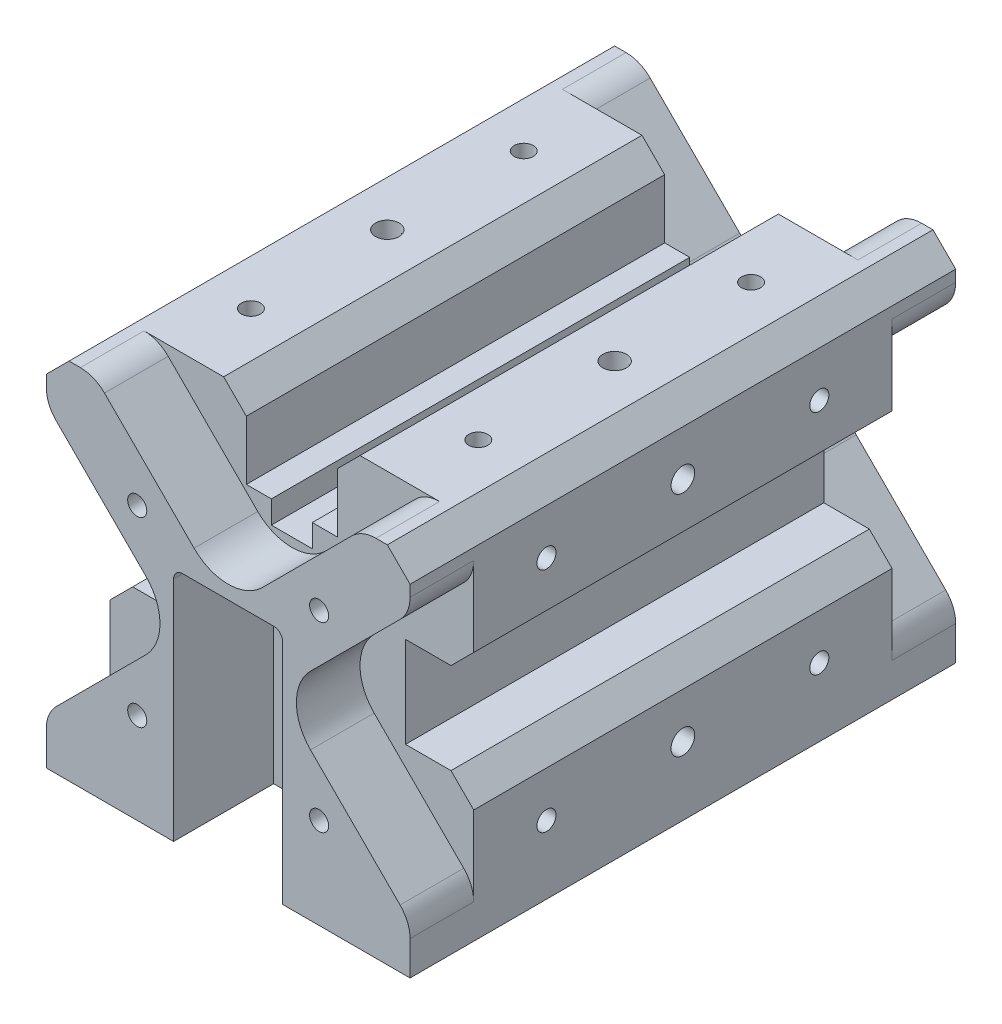
from build123d import *

# Parameters (mm, degrees)
SKETCH_7_W                = 80
SKETCH_7_H                = 80
EXTRUDE_2_DEPTH           = 120
CUT_EXTRUDE_2_DEPTH       = 22
CUT_EXTRUDE6_DEPTH        = 22
SKETCH5_R                 = 2
CUT_EXTRUDE8_DEPTH        = 10
SKETCH_10_R               = 2
CUT_EXTRUDE9_DEPTH        = 10
M3X0_5_TAPPED_HOLE1_D     = 2.5
M3X0_5_TAPPED_HOLE1_DEPTH = 7.5
M3X0_5_TAPPED_HOLE1_TIP   = 0.751075774
M5X0_8_TAPPED_HOLE2_D     = 4.2
M5X0_8_TAPPED_HOLE2_DEPTH = 19
M5X0_8_TAPPED_HOLE2_TIP   = 1.2618073
M5X0_8_TAPPED_HOLE5_D     = 4.2
M5X0_8_TAPPED_HOLE5_DEPTH = 12.4
M5X0_8_TAPPED_HOLE5_TIP   = 1.2618073
M5X0_8_TAPPED_HOLE3_D     = 4.2
M5X0_8_TAPPED_HOLE3_DEPTH = 12.4
M5X0_8_TAPPED_HOLE3_TIP   = 1.2618073
M5X0_8_TAPPED_HOLE4_D     = 4.2
M5X0_8_TAPPED_HOLE4_DEPTH = 12.4
M5X0_8_TAPPED_HOLE4_TIP   = 1.2618073
M3X0_5_TAPPED_HOLE4_D     = 2.5
M3X0_5_TAPPED_HOLE4_DEPTH = 5.5
M3X0_5_TAPPED_HOLE4_TIP   = 0.751075774
M3X0_5_TAPPED_HOLE5_D     = 2.5
M3X0_5_TAPPED_HOLE5_DEPTH = 5.5
M3X0_5_TAPPED_HOLE5_TIP   = 0.751075774
M5X0_8_TAPPED_HOLE1_D     = 4.2
M5X0_8_TAPPED_HOLE1_DEPTH = 19
M5X0_8_TAPPED_HOLE1_TIP   = 1.2618073
SKETCH33_R                = 2.6
CUT_EXTRUDE16_DEPTH       = 11
CUT_EXTRUDE16_TAPER       = 0.573055556
SKETCH34_R                = 2.6
CUT_EXTRUDE17_DEPTH       = 11
CUT_EXTRUDE17_TAPER       = 0.573055556
SKETCH35_R                = 2.6
CUT_EXTRUDE18_DEPTH       = 11
CUT_EXTRUDE18_TAPER       = 0.573055556
SKETCH63_OUTSIDE_W        = 114.984
SKETCH63_OUTSIDE_H        = 114.984
CUT_EXTRUDE19_DEPTH       = 121
CHAMFER1_SIZE             = 5
SKETCH_11_W               = 9
SKETCH_11_H               = 5
CUT_EXTRUDE_3_DEPTH       = 121
CUT_EXTRUDE_4_DEPTH       = 14
SKETCH64_OUTSIDE_W        = 114.984
SKETCH64_OUTSIDE_H        = 114.984
CUT_EXTRUDE_6_DEPTH       = 14


with BuildPart() as part:
    # Эскиз7 → Бобышка-Вытянуть2 (new body)
    with BuildSketch(Plane.XY):
        Rectangle(SKETCH_7_W, SKETCH_7_H)
    extrude(amount=EXTRUDE_2_DEPTH)

    # Эскиз8 → Вырез-Вытянуть2 (cut)
    with BuildSketch(Plane(origin=(0, 0, 0), x_dir=(-1, 0, 0), z_dir=(0, 0, -1))):
        with BuildLine():
            Line((-12, -10), (-12, 0))
            Line((-12, 0), (-12, 10))
            ThreePointArc((-12, 10), (-11.414213562, 11.414213562), (-10, 12))
            Line((-10, 12), (10, 12))
            ThreePointArc((10, 12), (11.414213562, 11.414213562), (12, 10))
            Line((12, 10), (12, 0))
            Line((12, 0), (12, -10))
            Line((12, -10), (12, -24))
            Line((12, -24), (12, -40))
            Line((12, -40), (-12, -40))
            Line((-12, -40), (-12, -24))
            Line((-12, -24), (-12, -10))
        make_face()
    extrude(amount=-CUT_EXTRUDE_2_DEPTH, mode=Mode.SUBTRACT)

    # Sketch4 → Cut-Extrude6 (cut)
    with BuildSketch(Plane.XY.offset(120)):
        with BuildLine():
            Line((-12, 10), (-12, 0))
            Line((-12, 0), (-12, -24))
            Line((-12, -24), (-12, -40))
            Line((-12, -40), (12, -40))
            Line((12, -40), (12, -24))
            Line((12, -24), (12, 0))
            Line((12, 0), (12, 10))
            ThreePointArc((12, 10), (11.414213562, 11.414213562), (10, 12))
            Line((10, 12), (-10, 12))
            ThreePointArc((-10, 12), (-11.414213562, 11.414213562), (-12, 10))
        make_face()
    extrude(amount=-CUT_EXTRUDE6_DEPTH, mode=Mode.SUBTRACT)

    # Sketch5 → Cut-Extrude8 (cut)
    with BuildSketch(Plane.XY.offset(98)):
        Circle(SKETCH5_R)
        with Locations((0, -24)):
            Circle(SKETCH5_R)
    extrude(amount=-CUT_EXTRUDE8_DEPTH, mode=Mode.SUBTRACT)

    # Эскиз10 → Cut-Extrude9 (cut)
    with BuildSketch(Plane(origin=(0, 0, 22), x_dir=(-1, 0, 0), z_dir=(0, 0, -1))):
        Circle(SKETCH_10_R)
        with Locations((0, -24)):
            Circle(SKETCH_10_R)
    extrude(amount=-CUT_EXTRUDE9_DEPTH, mode=Mode.SUBTRACT)

    # M3x0.5 Tapped Hole1
    with Locations(Plane(origin=(0, -40, 0), x_dir=(-1, 0, 0), z_dir=(0, -1, 0))):
        with Locations((-34, -6.4), (-10.886, -47.294), (-34, -113.588), (34.072, -113.588), (34.072, -6.4)):
            Hole(M3X0_5_TAPPED_HOLE1_D / 2, depth=M3X0_5_TAPPED_HOLE1_DEPTH)
            with Locations((0, 0, -(M3X0_5_TAPPED_HOLE1_DEPTH + M3X0_5_TAPPED_HOLE1_TIP / 2))):  # 118° drill point
                Cone(0, M3X0_5_TAPPED_HOLE1_D / 2, M3X0_5_TAPPED_HOLE1_TIP, mode=Mode.SUBTRACT)

    # M5x0.8 Tapped Hole2
    with Locations(Plane(origin=(0, 0, 0), x_dir=(-1, 0, 0), z_dir=(0, 0, -1))):
        with Locations((-20, 20), (20, 20), (20, -20), (-20, -20)):
            Hole(M5X0_8_TAPPED_HOLE2_D / 2, depth=M5X0_8_TAPPED_HOLE2_DEPTH)
            with Locations((0, 0, -(M5X0_8_TAPPED_HOLE2_DEPTH + M5X0_8_TAPPED_HOLE2_TIP / 2))):  # 118° drill point
                Cone(0, M5X0_8_TAPPED_HOLE2_D / 2, M5X0_8_TAPPED_HOLE2_TIP, mode=Mode.SUBTRACT)

    # M5x0.8 Tapped Hole5
    with Locations(Plane(origin=(40, 0, 0), x_dir=(0, 0, -1), z_dir=(1, 0, 0))):
        with Locations((-90, 25), (-30, 25), (-30, -25), (-90, -25)):
            Hole(M5X0_8_TAPPED_HOLE5_D / 2, depth=M5X0_8_TAPPED_HOLE5_DEPTH)
            with Locations((0, 0, -(M5X0_8_TAPPED_HOLE5_DEPTH + M5X0_8_TAPPED_HOLE5_TIP / 2))):  # 118° drill point
                Cone(0, M5X0_8_TAPPED_HOLE5_D / 2, M5X0_8_TAPPED_HOLE5_TIP, mode=Mode.SUBTRACT)

    # M5x0.8 Tapped Hole3
    with Locations(Plane(origin=(0, 40, 0), x_dir=(1, 0, 0), z_dir=(0, 1, 0))):
        with Locations((-25, -30), (25, -30), (25, -90), (-25, -90)):
            Hole(M5X0_8_TAPPED_HOLE3_D / 2, depth=M5X0_8_TAPPED_HOLE3_DEPTH)
            with Locations((0, 0, -(M5X0_8_TAPPED_HOLE3_DEPTH + M5X0_8_TAPPED_HOLE3_TIP / 2))):  # 118° drill point
                Cone(0, M5X0_8_TAPPED_HOLE3_D / 2, M5X0_8_TAPPED_HOLE3_TIP, mode=Mode.SUBTRACT)

    # M5x0.8 Tapped Hole4
    with Locations(Plane.ZY.offset(40)):
        with Locations((30, 25), (90, 25), (90, -25), (30, -25)):
            Hole(M5X0_8_TAPPED_HOLE4_D / 2, depth=M5X0_8_TAPPED_HOLE4_DEPTH)
            with Locations((0, 0, -(M5X0_8_TAPPED_HOLE4_DEPTH + M5X0_8_TAPPED_HOLE4_TIP / 2))):  # 118° drill point
                Cone(0, M5X0_8_TAPPED_HOLE4_D / 2, M5X0_8_TAPPED_HOLE4_TIP, mode=Mode.SUBTRACT)

    # M3x0.5 Tapped Hole4
    with Locations(Plane(origin=(0, 0, 22), x_dir=(-1, 0, 0), z_dir=(0, 0, -1))):
        with Locations((6, 0), (-6, 0), (-6, -24), (6, -24)):
            Hole(M3X0_5_TAPPED_HOLE4_D / 2, depth=M3X0_5_TAPPED_HOLE4_DEPTH)
            with Locations((0, 0, -(M3X0_5_TAPPED_HOLE4_DEPTH + M3X0_5_TAPPED_HOLE4_TIP / 2))):  # 118° drill point
                Cone(0, M3X0_5_TAPPED_HOLE4_D / 2, M3X0_5_TAPPED_HOLE4_TIP, mode=Mode.SUBTRACT)

    # M3x0.5 Tapped Hole5
    with Locations(Plane.XY.offset(98)):
        with Locations((6, 0), (-6, 0), (-6, -24), (6, -24)):
            Hole(M3X0_5_TAPPED_HOLE5_D / 2, depth=M3X0_5_TAPPED_HOLE5_DEPTH)
            with Locations((0, 0, -(M3X0_5_TAPPED_HOLE5_DEPTH + M3X0_5_TAPPED_HOLE5_TIP / 2))):  # 118° drill point
                Cone(0, M3X0_5_TAPPED_HOLE5_D / 2, M3X0_5_TAPPED_HOLE5_TIP, mode=Mode.SUBTRACT)

    # M5x0.8 Tapped Hole1
    with Locations(Plane.XY.offset(120)):
        with Locations((-20, 20), (20, 20), (20, -20), (-20, -20)):
            Hole(M5X0_8_TAPPED_HOLE1_D / 2, depth=M5X0_8_TAPPED_HOLE1_DEPTH)
            with Locations((0, 0, -(M5X0_8_TAPPED_HOLE1_DEPTH + M5X0_8_TAPPED_HOLE1_TIP / 2))):  # 118° drill point
                Cone(0, M5X0_8_TAPPED_HOLE1_D / 2, M5X0_8_TAPPED_HOLE1_TIP, mode=Mode.SUBTRACT)

    # Sketch33 → Cut-Extrude16 (cut)
    with BuildSketch(Plane(origin=(40, 0, 0), x_dir=(0, 0, -1), z_dir=(1, 0, 0))):
        with Locations((-60, -25)):
            Circle(SKETCH33_R)
        with Locations((-60, 25)):
            Circle(SKETCH33_R)
    extrude(amount=-CUT_EXTRUDE16_DEPTH, taper=CUT_EXTRUDE16_TAPER, mode=Mode.SUBTRACT)

    # Sketch34 → Cut-Extrude17 (cut)
    with BuildSketch(Plane(origin=(0, 40, 0), x_dir=(1, 0, 0), z_dir=(0, 1, 0))):
        with Locations((-25, -60)):
            Circle(SKETCH34_R)
        with Locations((25, -60)):
            Circle(SKETCH34_R)
    extrude(amount=-CUT_EXTRUDE17_DEPTH, taper=CUT_EXTRUDE17_TAPER, mode=Mode.SUBTRACT)

    # Sketch35 → Cut-Extrude18 (cut)
    with BuildSketch(Plane.ZY.offset(40)):
        with Locations((60, -25)):
            Circle(SKETCH35_R)
        with Locations((60, 25)):
            Circle(SKETCH35_R)
    extrude(amount=-CUT_EXTRUDE18_DEPTH, taper=CUT_EXTRUDE18_TAPER, mode=Mode.SUBTRACT)

    # Sketch63 outside → Cut-Extrude19 (cut, through all)
    with BuildSketch(Plane(origin=(0, 0, 0), x_dir=(-1, 0, 0), z_dir=(0, 0, -1))):
        Rectangle(SKETCH63_OUTSIDE_W, SKETCH63_OUTSIDE_H)
        Polygon((-40, 10), (-25, 10), (-25, -10), (-40, -10), (-40, -40), (40, -40), (40, -10), (25, -10), (25, 10), (40, 10), (40, 40), (10, 40), (10, 22), (-10, 22), (-10, 40), (-40, 40), align=None, mode=Mode.SUBTRACT)
    extrude(amount=-CUT_EXTRUDE19_DEPTH, mode=Mode.SUBTRACT)

    # Chamfer1
    chamfer1_edges = [part.edges().sort_by_distance(p)[0] for p in [
        (40, -10, 60),
        (10, 40, 60),
        (-40, 10, 60),
        (-40, -10, 60),
        (40, 10, 60),
        (-10, 40, 60),
        (-40, 40, 60),
        (40, 40, 60),
    ]]
    chamfer(chamfer1_edges, length=CHAMFER1_SIZE)

    # Эскиз11 → Вырез-Вытянуть3 (cut, through all)
    with BuildSketch(Plane.XY.offset(120)):
        with Locations((0, 19.5)):
            Rectangle(SKETCH_11_W, SKETCH_11_H)
    extrude(amount=-CUT_EXTRUDE_3_DEPTH, mode=Mode.SUBTRACT)

    # Sketch65 → Вырез-Вытянуть4 (cut)
    with BuildSketch(Plane.XY.offset(120)):
        with BuildLine():
            Line((-32.5, 40), (32.5, 40))
            ThreePointArc((32.5, 40), (29.629874257, 39.429096494), (27.196699141, 37.803300859))
            Line((27.196699141, 37.803300859), (7.5, 18.106601718))
            ThreePointArc((7.5, 18.106601718), (0, 15), (-7.5, 18.106601718))
            Line((-7.5, 18.106601718), (-27.196699141, 37.803300859))
            ThreePointArc((-27.196699141, 37.803300859), (-29.629874257, 39.429096494), (-32.5, 40))
        make_face()
        with BuildLine():
            Line((40, 32.5), (40, -32.5))
            ThreePointArc((40, -32.5), (39.429096494, -29.629874257), (37.803300859, -27.196699141))
            Line((37.803300859, -27.196699141), (18.106601718, -7.5))
            ThreePointArc((18.106601718, -7.5), (15, 0), (18.106601718, 7.5))
            Line((18.106601718, 7.5), (37.803300859, 27.196699141))
            ThreePointArc((37.803300859, 27.196699141), (39.429096494, 29.629874257), (40, 32.5))
        make_face()
        with BuildLine():
            Line((-40, 32.5), (-40, -32.5))
            ThreePointArc((-40, -32.5), (-39.429096494, -29.629874257), (-37.803300859, -27.196699141))
            Line((-37.803300859, -27.196699141), (-18.106601718, -7.5))
            ThreePointArc((-18.106601718, -7.5), (-15, 0), (-18.106601718, 7.5))
            Line((-18.106601718, 7.5), (-37.803300859, 27.196699141))
            ThreePointArc((-37.803300859, 27.196699141), (-39.429096494, 29.629874257), (-40, 32.5))
        make_face()
    extrude(amount=-CUT_EXTRUDE_4_DEPTH, mode=Mode.SUBTRACT)

    # Sketch64 outside → Вырез-Вытянуть6 (cut)
    with BuildSketch(Plane(origin=(0, 0, 0), x_dir=(-1, 0, 0), z_dir=(0, 0, -1))):
        Rectangle(SKETCH64_OUTSIDE_W, SKETCH64_OUTSIDE_H)
        with BuildLine():
            Line((40, -32.5), (40, -40))
            Line((40, -40), (-40, -40))
            Line((-40, -40), (-40, -32.5))
            ThreePointArc((-40, -32.5), (-39.429096494, -29.629874257), (-37.803300859, -27.196699141))
            Line((-37.803300859, -27.196699141), (-18.106601653, -7.499999935))
            ThreePointArc((-18.106601653, -7.499999935), (-14.999999962, 0), (-18.106601653, 7.499999935))
            Line((-18.106601653, 7.499999935), (-37.803300859, 27.196699141))
            ThreePointArc((-37.803300859, 27.196699141), (-39.429096494, 29.629874257), (-40, 32.5))
            Line((-40, 32.5), (-40, 40))
            Line((-40, 40), (-32.5, 40))
            ThreePointArc((-32.5, 40), (-29.629874257, 39.429096494), (-27.196699141, 37.803300859))
            Line((-27.196699141, 37.803300859), (-7.499999935, 18.106601653))
            ThreePointArc((-7.499999935, 18.106601653), (0, 14.999999962), (7.499999935, 18.106601653))
            Line((7.499999935, 18.106601653), (27.196699141, 37.803300859))
            ThreePointArc((27.196699141, 37.803300859), (29.629874257, 39.429096494), (32.5, 40))
            Line((32.5, 40), (40, 40))
            Line((40, 40), (40, 32.5))
            ThreePointArc((40, 32.5), (39.429096494, 29.629874257), (37.803300859, 27.196699141))
            Line((37.803300859, 27.196699141), (18.106601653, 7.499999935))
            ThreePointArc((18.106601653, 7.499999935), (14.999999962, 0), (18.106601653, -7.499999935))
            Line((18.106601653, -7.499999935), (37.803300859, -27.196699141))
            ThreePointArc((37.803300859, -27.196699141), (39.429096494, -29.629874257), (40, -32.5))
        make_face(mode=Mode.SUBTRACT)
    extrude(amount=-CUT_EXTRUDE_6_DEPTH, mode=Mode.SUBTRACT)


solid = part.part
